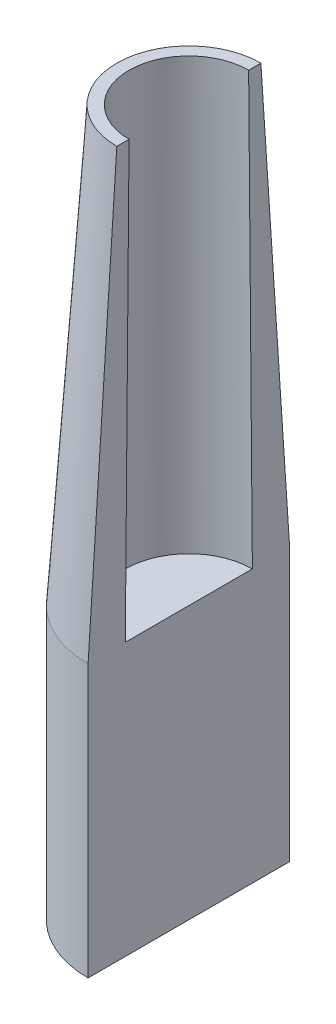
from build123d import *

# Parameters (mm, degrees)
SKETCH2_R                = 25.4
BOSS_EXTRUDE1_DEPTH      = 63.5
BOSS_EXTRUDE1_DEPTH_BACK = 5.08
SKETCH3_R                = 25.4
BOSS_EXTRUDE2_DEPTH      = 109.317536
BOSS_EXTRUDE2_TAPER      = 3.79256
SKETCH4_R                = 15.06855
CUT_EXTRUDE1_DEPTH       = 109.317536
CUT_EXTRUDE1_DRAFT       = 0.49256
SPLIT2_SURFACE_1_BACK    = 192.856
SPLIT2_SURFACE_1_DEPTH   = 385.712


with BuildPart() as part:
    # Sketch2 → Boss-Extrude1 (new, two sides)
    with BuildSketch(Plane(origin=(0, 0, 0), x_dir=(1, 0, 0), z_dir=(0, 1, 0))) as boss_extrude1_sk:
        with Locations(Location((0, 0, 0), (0, 0, 270))):
            Circle(SKETCH2_R)
    extrude(amount=BOSS_EXTRUDE1_DEPTH)
    extrude(boss_extrude1_sk.sketch, amount=-BOSS_EXTRUDE1_DEPTH_BACK)

    # Sketch3 → Boss-Extrude2 (add)
    with BuildSketch(Plane(origin=(0, 63.5, 0), x_dir=(1, 0, 0), z_dir=(0, 1, 0))):
        with Locations(Location((0, 0, 0), (0, 0, 270))):
            Circle(SKETCH3_R)
    extrude(amount=BOSS_EXTRUDE2_DEPTH, taper=BOSS_EXTRUDE2_TAPER)


with BuildPart() as cut_extrude1_tool:
    # Sketch4 → Cut-Extrude1 (with draft: the straight prism first)
    with BuildSketch(Plane(origin=(0, 172.817536, 0), x_dir=(1, 0, 0), z_dir=(0, 1, 0))):
        Circle(SKETCH4_R)
    extrude(amount=-CUT_EXTRUDE1_DEPTH)
    # Cut-Extrude1: the draft: its side faces are tilted about the plane it starts from
    cut_extrude1_sides = [cut_extrude1_tool.faces().sort_by_distance(p)[0] for p in [
        (-15.06855, 118.158768, 0),
    ]]
    draft(cut_extrude1_sides, Plane(origin=(0, 172.817536, 0), x_dir=(1, 0, 0), z_dir=(0, 1, 0)), CUT_EXTRUDE1_DRAFT)


with BuildPart() as part_1:
    add(part.part)

    # Cut-Extrude1: cut by cut_extrude1_tool
    add(cut_extrude1_tool.part, mode=Mode.SUBTRACT)

    # Split2: cut with a surface, the side behind it stays
    # Split2 surface: a surface, the sketch's curves swept straight by 385.712 mm
    with BuildLine(Plane(origin=(0, 0, 0), x_dir=(1, 0, 0), z_dir=(0, 1, 0)).offset(-SPLIT2_SURFACE_1_BACK), mode=Mode.PRIVATE) as split2_surface_1_path:
        Line((0, 25.4), (0, -25.4))
    split2_surface_1 = Shell.extrude(split2_surface_1_path.wire(), (0 * SPLIT2_SURFACE_1_DEPTH, 1 * SPLIT2_SURFACE_1_DEPTH, 0 * SPLIT2_SURFACE_1_DEPTH))
    split(bisect_by=split2_surface_1, keep=Keep.BOTTOM)


solid = part_1.part
